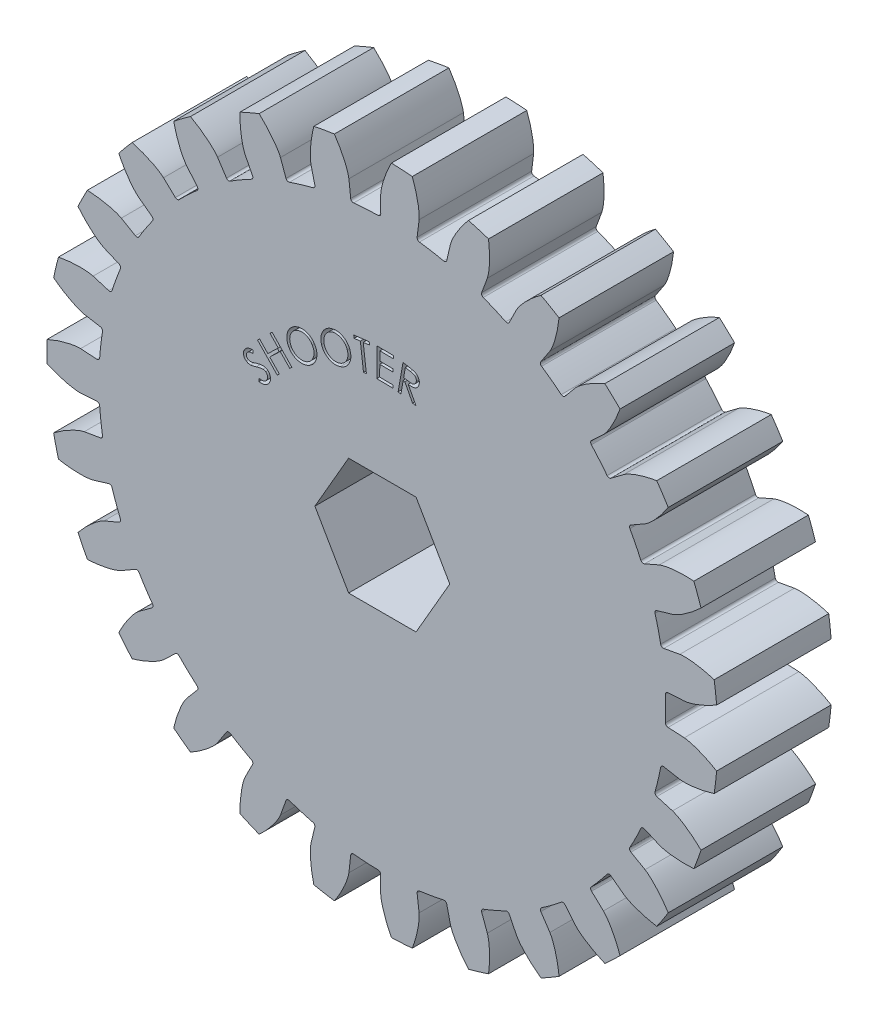
from build123d import *

# Parameters (mm, degrees)
SKETCH1_R              = 37.202020202
BODYBLANK_DEPTH        = 12.7
TOOTHCUTMASTER_DEPTH   = 13.7
TOOTHCUTSPATTERN_COUNT = 27
CUT_EXTRUDE1_DEPTH     = 13.7000001
SHOOTER_DEPTH          = 1.27


with BuildPart() as part:
    # Sketch1 → BodyBlank (new body)
    with BuildSketch(Plane.XY):
        Circle(SKETCH1_R)
    extrude(amount=BODYBLANK_DEPTH)

    # EqDrivenInvoluteCurves → ToothCutMaster (cut, through all)
    with BuildSketch(Plane.XY.offset(12.7)):
        with BuildLine():
            Line((31.681619769, 1.6690338), (33.486677538, 1.764126868))
            add(Edge.make_bspline(
                [(33.486677538, 1.764126868), (33.492388197, 1.764485944), (33.50839531, 1.765672924), (33.538618099, 1.768627279), (33.58787541, 1.774457047), (33.650547397, 1.78336854), (33.731442881, 1.796590504), (33.826591419, 1.814357912), (33.930994408, 1.836180458), (34.044395442, 1.862401828), (34.15735783, 1.890754256), (34.269875909, 1.921078839), (34.381804891, 1.953128433), (34.517192773, 1.994127781), (34.679259957, 2.046315997), (34.868267652, 2.111726934), (35.082113124, 2.191118913), (35.299479381, 2.277603643), (35.512882182, 2.367282562), (35.72791402, 2.463158514), (35.935554052, 2.559655249), (36.150605398, 2.665286344), (36.348791798, 2.765534392), (36.570117434, 2.883829579), (36.748521521, 2.981040043), (36.932199912, 3.086449102), (37.021506506, 3.138489053), (37.067109149, 3.165395146)],
                knots=[0, 0, 0, 0, 0, 0.005376749, 0.015083688, 0.02853182, 0.04661014, 0.064854849, 0.092110526, 0.119476176, 0.146842496, 0.174208854, 0.201574956, 0.228941013, 0.256307345, 0.307035032, 0.361767352, 0.416499661, 0.471231937, 0.525964282, 0.580696616, 0.635428982, 0.690161387, 0.744893688, 0.799626082, 0.854358407, 0.909090914, 0.909090914, 0.909090914, 0.909090914, 0.909090914], degree=4))
            ThreePointArc((37.067109149, 3.165395146), (37.202020202, 0), (37.067109149, -3.165395146))
            add(Edge.make_bspline(
                [(33.486677538, -1.764126868), (33.492388197, -1.764485944), (33.50839531, -1.765672924), (33.538618099, -1.768627279), (33.58787541, -1.774457047), (33.650547397, -1.78336854), (33.731442881, -1.796590504), (33.826591419, -1.814357912), (33.930994408, -1.836180458), (34.044395442, -1.862401828), (34.15735783, -1.890754256), (34.269875909, -1.921078839), (34.381804891, -1.953128433), (34.517192773, -1.994127781), (34.679259957, -2.046315997), (34.868267652, -2.111726934), (35.082113124, -2.191118913), (35.299479381, -2.277603643), (35.512882182, -2.367282562), (35.72791402, -2.463158514), (35.935554052, -2.559655249), (36.150605398, -2.665286344), (36.348791798, -2.765534392), (36.570117434, -2.883829579), (36.748521521, -2.981040043), (36.932199912, -3.086449102), (37.021506506, -3.138489053), (37.067109149, -3.165395146)],
                knots=[0, 0, 0, 0, 0, 0.005376749, 0.015083688, 0.02853182, 0.04661014, 0.064854849, 0.092110526, 0.119476176, 0.146842496, 0.174208854, 0.201574956, 0.228941013, 0.256307345, 0.307035032, 0.361767352, 0.416499661, 0.471231937, 0.525964282, 0.580696616, 0.635428982, 0.690161387, 0.744893688, 0.799626082, 0.854358407, 0.909090914, 0.909090914, 0.909090914, 0.909090914, 0.909090914], degree=4))
            Line((33.486677538, -1.764126868), (31.681619769, -1.6690338))
            ThreePointArc((31.681619769, -1.6690338), (31.47695942, -1.571935981), (31.399901128, -1.358919867))
            ThreePointArc((31.399901128, -1.358919867), (31.429292929, 0), (31.399901128, 1.358919867))
            ThreePointArc((31.399901128, 1.358919867), (31.47695942, 1.571935981), (31.681619769, 1.6690338))
        make_face()
    toothcutmaster = extrude(amount=-TOOTHCUTMASTER_DEPTH, mode=Mode.SUBTRACT)

    # ToothCutsPattern: ToothCutMaster ×27 about axis
    toothcutspattern_axis = Axis((0, 0, 12.7), (0, 0, -1))
    for i in range(1, TOOTHCUTSPATTERN_COUNT):
        add(toothcutmaster.rotate(toothcutspattern_axis, i * 360 / TOOTHCUTSPATTERN_COUNT), mode=Mode.SUBTRACT)

    # Sketch2 → Cut-Extrude1 (cut, through all)
    with BuildSketch(Plane.XY.offset(12.7)):
        Polygon((3.739497694, 6.477), (-3.739497694, 6.477), (-7.478995387, 0), (-3.739497694, -6.477), (3.739497694, -6.477), (7.478995387, 0), align=None)
    extrude(amount=-CUT_EXTRUDE1_DEPTH, mode=Mode.SUBTRACT)

    # Sketch3 → Shooter (cut)
    with BuildSketch(Plane.XY.offset(12.7)):
        with BuildLine():
            Line((-13.676549152, 8.860884825), (-13.649200394, 9.171897445))
            add(Edge.make_bspline(
                [(-13.649200394, 9.171897445), (-13.602408385, 9.166680453), (-13.51261279, 9.156668852), (-13.38270523, 9.154427095), (-13.264172616, 9.164295133), (-13.156873614, 9.185280047), (-13.061029192, 9.219099513), (-12.976385867, 9.26429037), (-12.903310114, 9.322295907), (-12.864626466, 9.369577776), (-12.845274112, 9.393231579)],
                knots=[0, 0, 0, 0, 0.000141193, 0.000270955, 0.000389057, 0.000497451, 0.000598034, 0.000692803, 0.000784186, 0.000875669, 0.000875669, 0.000875669, 0.000875669], degree=3))
            add(Edge.make_bspline(
                [(-12.845274112, 9.393231579), (-12.830706223, 9.414942367), (-12.801855038, 9.457939808), (-12.768899273, 9.52805102), (-12.744293446, 9.601228011), (-12.729540513, 9.676933843), (-12.722690955, 9.752901013), (-12.726398022, 9.826998905), (-12.740445875, 9.898213003), (-12.765136941, 9.965151988), (-12.796186134, 10.028393193), (-12.836626395, 10.084534587), (-12.882196025, 10.135870749), (-12.918156655, 10.163962817), (-12.936224633, 10.178077333)],
                knots=[0, 0, 0, 0, 7.8341e-05, 0.000155152, 0.00023158, 0.000309414, 0.000386, 0.000459877, 0.000531225, 0.000602844, 0.000673384, 0.00074185, 0.000809833, 0.000878481, 0.000878481, 0.000878481, 0.000878481], degree=3))
            add(Edge.make_bspline(
                [(-12.936224633, 10.178077333), (-12.958266241, 10.192453363), (-13.002917895, 10.221576171), (-13.079209415, 10.25086524), (-13.162145615, 10.269915444), (-13.219988696, 10.272687976), (-13.249781324, 10.274115995)],
                knots=[0, 0, 0, 0, 7.8753e-05, 0.000159538, 0.000243631, 0.000332948, 0.000332948, 0.000332948, 0.000332948], degree=3))
            add(Edge.make_bspline(
                [(-13.249781324, 10.274115995), (-13.272263415, 10.273959225), (-13.319418096, 10.273630413), (-13.393547326, 10.26755283), (-13.474131241, 10.256486648), (-13.561504783, 10.241042386), (-13.655464981, 10.221293058), (-13.755951625, 10.196952637), (-13.863136563, 10.168411627), (-13.936319321, 10.146283615), (-13.974205402, 10.134828134)],
                knots=[0, 0, 0, 0, 6.743e-05, 0.00014143, 0.000222924, 0.000311386, 0.000407559, 0.000510915, 0.000621533, 0.000740266, 0.000740266, 0.000740266, 0.000740266], degree=3))
            add(Edge.make_bspline(
                [(-13.974205402, 10.134828134), (-14.011885487, 10.123392973), (-14.083872657, 10.101546289), (-14.187606508, 10.073446187), (-14.281325363, 10.048034062), (-14.365575468, 10.027958409), (-14.440078047, 10.01138812), (-14.505127146, 10.000953393), (-14.560431116, 9.993068278), (-14.594302591, 9.991703846), (-14.609587013, 9.99108815)],
                knots=[0, 0, 0, 0, 0.000118123, 0.000225672, 0.000322401, 0.000409405, 0.000485499, 0.000551268, 0.000607042, 0.000652906, 0.000652906, 0.000652906, 0.000652906], degree=3))
            add(Edge.make_bspline(
                [(-14.609587013, 9.99108815), (-14.632497937, 9.991139315), (-14.677569188, 9.99123997), (-14.74415427, 9.997807874), (-14.808319923, 10.009300949), (-14.870509648, 10.025139564), (-14.930530837, 10.046207394), (-14.988266306, 10.072402111), (-15.044247922, 10.102872733), (-15.079174433, 10.127080268), (-15.096776516, 10.139280257)],
                knots=[0, 0, 0, 0, 6.8702e-05, 0.000135153, 0.000200403, 0.000264112, 0.000327475, 0.000390956, 0.000454153, 0.000518362, 0.000518362, 0.000518362, 0.000518362], degree=3))
            add(Edge.make_bspline(
                [(-15.096776516, 10.139280257), (-15.123247439, 10.159789511), (-15.175480361, 10.200258757), (-15.242486536, 10.27229959), (-15.29842488, 10.351601376), (-15.343765691, 10.437111831), (-15.376022389, 10.528271011), (-15.396031691, 10.622794096), (-15.403071947, 10.720158752), (-15.396467838, 10.819155858), (-15.377302892, 10.917608738), (-15.346394036, 11.013418768), (-15.301796177, 11.104844494), (-15.26408442, 11.161342817), (-15.244968624, 11.189981379)],
                knots=[0, 0, 0, 0, 0.00010033, 0.000197972, 0.000293794, 0.000390807, 0.000487368, 0.000582919, 0.000679847, 0.000779269, 0.000879682, 0.000980045, 0.001080458, 0.001183677, 0.001183677, 0.001183677, 0.001183677], degree=3))
            add(Edge.make_bspline(
                [(-15.244968624, 11.189981379), (-15.222411396, 11.218855738), (-15.177751313, 11.276022835), (-15.097417976, 11.349708782), (-15.00848348, 11.412076761), (-14.927433723, 11.455805256), (-14.856805717, 11.484126289), (-14.7985123, 11.503500403), (-14.734892855, 11.519154071), (-14.666228154, 11.531584444), (-14.592601215, 11.541802834), (-14.514104053, 11.549372012), (-14.430283904, 11.553891368), (-14.372782264, 11.554239664), (-14.343095627, 11.55441948)],
                knots=[0, 0, 0, 0, 0.000109773, 0.000217336, 0.000325505, 0.00043505, 0.000492686, 0.000553628, 0.000619187, 0.000689045, 0.000762891, 0.000842126, 0.000925563, 0.001014615, 0.001014615, 0.001014615, 0.001014615], degree=3))
            Line((-14.343095627, 11.55441948), (-14.336099433, 11.23259456))
            add(Edge.make_bspline(
                [(-14.336099433, 11.23259456), (-14.359848861, 11.231859434), (-14.405673926, 11.230440992), (-14.471836176, 11.226567948), (-14.532960409, 11.221721449), (-14.589020206, 11.21488684), (-14.640074895, 11.205726369), (-14.686343573, 11.196134674), (-14.727423763, 11.183726307), (-14.775457518, 11.166399716), (-14.829157979, 11.138675548), (-14.888315694, 11.099027551), (-14.940630328, 11.050311411), (-14.970447849, 11.012926749), (-14.985473431, 10.99408795)],
                knots=[0, 0, 0, 0, 7.1279e-05, 0.000137535, 0.000198805, 0.00025521, 0.000306864, 0.000354396, 0.000396857, 0.000435492, 0.000507455, 0.000577489, 0.000648598, 0.00072083, 0.00072083, 0.00072083, 0.00072083], degree=3))
            add(Edge.make_bspline(
                [(-14.985473431, 10.99408795), (-15.002407198, 10.968792631), (-15.035063496, 10.920011312), (-15.066051161, 10.839146091), (-15.0805596, 10.757023217), (-15.077765416, 10.674850524), (-15.059885622, 10.596094803), (-15.025688306, 10.524513144), (-14.978130771, 10.460446752), (-14.936682993, 10.426783116), (-14.915511492, 10.409587749)],
                knots=[0, 0, 0, 0, 9.1084e-05, 0.000175653, 0.00025763, 0.000339716, 0.00042071, 0.000498095, 0.000576199, 0.00065775, 0.00065775, 0.00065775, 0.00065775], degree=3))
            add(Edge.make_bspline(
                [(-14.915511492, 10.409587749), (-14.901496891, 10.400152045), (-14.873468795, 10.381281381), (-14.828035178, 10.35873723), (-14.780562262, 10.339721976), (-14.729528159, 10.32644097), (-14.67350518, 10.31769302), (-14.611249212, 10.31680734), (-14.54209942, 10.319510712), (-14.494212285, 10.326440814), (-14.469027117, 10.330085546)],
                knots=[0, 0, 0, 0, 5.0634e-05, 0.000101265, 0.000151815, 0.000203805, 0.000259124, 0.000321483, 0.000390247, 0.000466532, 0.000466532, 0.000466532, 0.000466532], degree=3))
            add(Edge.make_bspline(
                [(-14.469027117, 10.330085546), (-14.460326457, 10.331956253), (-14.439459906, 10.336442719), (-14.403159109, 10.345431283), (-14.356571189, 10.358379781), (-14.299985223, 10.374781035), (-14.23319203, 10.394680368), (-14.156541531, 10.418315971), (-14.069281577, 10.444835518), (-14.007895082, 10.464223128), (-13.975477438, 10.474461547)],
                knots=[0, 0, 0, 0, 2.6698e-05, 6.4028e-05, 0.000112168, 0.000171751, 0.000240773, 0.000321248, 0.000412385, 0.000514373, 0.000514373, 0.000514373, 0.000514373], degree=3))
            add(Edge.make_bspline(
                [(-13.975477438, 10.474461547), (-13.93631613, 10.486533257), (-13.860389599, 10.509938068), (-13.749133157, 10.540666071), (-13.644065485, 10.565436428), (-13.545453813, 10.585369617), (-13.453366639, 10.600013729), (-13.367665996, 10.610076665), (-13.288195131, 10.613888017), (-13.214253442, 10.612740095), (-13.145045493, 10.606812514), (-13.079070389, 10.597623911), (-13.016176055, 10.583125589), (-12.955481985, 10.566610774), (-12.898221221, 10.544374262), (-12.843037081, 10.519862804), (-12.790764966, 10.490524963), (-12.75797436, 10.467932583), (-12.741603239, 10.456653054)],
                knots=[0, 0, 0, 0, 0.000122936, 0.00023835, 0.000346184, 0.000446719, 0.000540095, 0.000625854, 0.000705447, 0.0007786, 0.000847528, 0.000913729, 0.000978231, 0.001041046, 0.001102236, 0.001162295, 0.001222094, 0.001281717, 0.001281717, 0.001281717, 0.001281717], degree=3))
            add(Edge.make_bspline(
                [(-12.741603239, 10.456653054), (-12.719417602, 10.439474519), (-12.675646555, 10.405582211), (-12.616495626, 10.347805544), (-12.56522513, 10.284378464), (-12.519445572, 10.217243979), (-12.482498106, 10.144082022), (-12.45198717, 10.066595434), (-12.428375947, 9.983947903), (-12.412256495, 9.897718378), (-12.402907667, 9.809837885), (-12.403388101, 9.722528142), (-12.410425204, 9.637010353), (-12.427439367, 9.553274965), (-12.452788185, 9.471442896), (-12.486912825, 9.391469562), (-12.529002603, 9.313255271), (-12.562839203, 9.26382744), (-12.580054761, 9.238679296)],
                knots=[0, 0, 0, 0, 8.4132e-05, 0.000165989, 0.000247344, 0.000328488, 0.000409272, 0.000492656, 0.000578011, 0.0006667, 0.000755554, 0.000842689, 0.000928256, 0.001012576, 0.001098476, 0.001184829, 0.00127305, 0.001364427, 0.001364427, 0.001364427, 0.001364427], degree=3))
            add(Edge.make_bspline(
                [(-12.580054761, 9.238679296), (-12.594406813, 9.219795286), (-12.622753549, 9.182497481), (-12.669703973, 9.131005982), (-12.718505467, 9.082873288), (-12.771084337, 9.039593217), (-12.82624796, 9.000120943), (-12.88459549, 8.964987833), (-12.945535016, 8.933835761), (-13.009662441, 8.906819251), (-13.077516169, 8.884568009), (-13.149730364, 8.866544686), (-13.226578309, 8.85427214), (-13.307904313, 8.845994545), (-13.393700599, 8.842114691), (-13.484121841, 8.843824447), (-13.579039819, 8.849201522), (-13.643509001, 8.856926044), (-13.676549152, 8.860884825)],
                knots=[0, 0, 0, 0, 7.1123e-05, 0.000140475, 0.000208841, 0.000276594, 0.00034454, 0.000412168, 0.000480719, 0.000549703, 0.000620701, 0.000694744, 0.000772747, 0.000853943, 0.00093989, 0.001030214, 0.001125153, 0.001224959, 0.001224959, 0.001224959, 0.001224959], degree=3))
        make_face()
        Polygon((-13.846816766, 12.777965994), (-13.617214403, 12.998664111), (-12.696260877, 12.042093598), (-11.536800741, 13.157668518), (-12.457754266, 14.114239031), (-12.228151903, 14.335573165), (-10.033255068, 12.054813951), (-10.262857431, 11.833479816), (-11.3224628, 12.934426331), (-12.481922936, 11.818851411), (-11.422317568, 10.717904896), (-11.651919931, 10.497206779), align=None)
        with BuildLine():
            add(Edge.make_bspline(
                [(-9.794914784, 16.074500039), (-9.743699079, 16.103488778), (-9.643273454, 16.160330957), (-9.486035071, 16.227249705), (-9.327572254, 16.277716806), (-9.16774008, 16.312852634), (-9.006017765, 16.328912748), (-8.843276627, 16.32973514), (-8.678911428, 16.313803023), (-8.515387069, 16.280277025), (-8.355414689, 16.233500954), (-8.203397107, 16.171428833), (-8.060576826, 16.096231832), (-7.927559869, 16.00663976), (-7.804288105, 15.90305321), (-7.690878883, 15.785656932), (-7.585289701, 15.655927236), (-7.525461546, 15.560229152), (-7.49507504, 15.511624438)],
                knots=[0, 0, 0, 0, 0.000176442, 0.000345974, 0.000511516, 0.000674809, 0.000835936, 0.000998122, 0.00116235, 0.001330366, 0.001498199, 0.001661661, 0.001822125, 0.001981592, 0.002141855, 0.002304224, 0.0024707, 0.002642519, 0.002642519, 0.002642519, 0.002642519], degree=3))
            add(Edge.make_bspline(
                [(-7.49507504, 15.511624438), (-7.467191281, 15.462080473), (-7.41217559, 15.364328389), (-7.347287065, 15.211098611), (-7.299331177, 15.055656524), (-7.267383586, 14.898434982), (-7.250936381, 14.739050431), (-7.252858654, 14.577498034), (-7.269946016, 14.413884014), (-7.303841204, 14.250481493), (-7.351548508, 14.090713018), (-7.413184804, 13.938323771), (-7.489460315, 13.796107284), (-7.578075979, 13.662666288), (-7.681217542, 13.539547705), (-7.797461191, 13.425929394), (-7.927333817, 13.322030004), (-8.021944886, 13.262009307), (-8.070034976, 13.231501241)],
                knots=[0, 0, 0, 0, 0.000170454, 0.000336312, 0.000498058, 0.000657717, 0.000816882, 0.0009778, 0.001141523, 0.001309665, 0.001477681, 0.001641143, 0.001801905, 0.001961018, 0.002120872, 0.002282786, 0.002447971, 0.002618727, 0.002618727, 0.002618727, 0.002618727], degree=3))
            add(Edge.make_bspline(
                [(-8.070034976, 13.231501241), (-8.120192758, 13.203142993), (-8.218923021, 13.147322794), (-8.373699172, 13.082136822), (-8.529858377, 13.032353774), (-8.688066952, 12.999825316), (-8.848328632, 12.984043507), (-9.010324446, 12.983639936), (-9.174050319, 13.001629023), (-9.337620938, 13.034292184), (-9.497042409, 13.082244224), (-9.64896035, 13.143557066), (-9.791278678, 13.217713695), (-9.923259047, 13.306557193), (-10.045772202, 13.407777897), (-10.158211417, 13.522647511), (-10.26160096, 13.65017642), (-10.320756131, 13.743704616), (-10.350794191, 13.791196754)],
                knots=[0, 0, 0, 0, 0.000172737, 0.000340015, 0.000502747, 0.00066378, 0.000823577, 0.000985126, 0.001148849, 0.001316865, 0.001484881, 0.001647514, 0.001807682, 0.001965383, 0.002123936, 0.002283596, 0.002446894, 0.002615357, 0.002615357, 0.002615357, 0.002615357], degree=3))
            add(Edge.make_bspline(
                [(-10.350794191, 13.791196754), (-10.369446457, 13.823834109), (-10.406642634, 13.888919222), (-10.454522602, 13.989700479), (-10.495822339, 14.092215082), (-10.529040486, 14.196545505), (-10.557185342, 14.302492265), (-10.576125449, 14.41044709), (-10.590175901, 14.519922301), (-10.595517911, 14.630473623), (-10.594088711, 14.741099723), (-10.586961894, 14.850373706), (-10.571445327, 14.957659674), (-10.548955477, 15.062713695), (-10.520682022, 15.166230363), (-10.484035267, 15.267125841), (-10.441383251, 15.366550637), (-10.391241134, 15.463009865), (-10.335424208, 15.556638938), (-10.273711164, 15.645606383), (-10.206818879, 15.729770565), (-10.134814145, 15.80884796), (-10.057481391, 15.882780902), (-9.975398596, 15.952161966), (-9.888135673, 16.017005448), (-9.826162807, 16.055227617), (-9.794914784, 16.074500039)],
                knots=[0, 0, 0, 0, 0.00011274, 0.000224826, 0.000334428, 0.000444046, 0.00055311, 0.000663016, 0.000772592, 0.000884042, 0.000994716, 0.001104377, 0.001212313, 0.001319591, 0.001426527, 0.001533956, 0.001641354, 0.001750871, 0.001859838, 0.001968165, 0.002075441, 0.002182142, 0.002288753, 0.002396166, 0.00250442, 0.002614517, 0.002614517, 0.002614517, 0.002614517], degree=3))
        make_face()
        with BuildLine():
            add(Edge.make_bspline(
                [(-9.623190024, 15.815640865), (-9.647781371, 15.800268066), (-9.696937751, 15.769538918), (-9.766568268, 15.718003726), (-9.83249605, 15.662417654), (-9.894502093, 15.602430723), (-9.952201152, 15.537702641), (-10.005536648, 15.468431542), (-10.05648643, 15.396043652), (-10.101406823, 15.318558402), (-10.143078135, 15.239140273), (-10.177724549, 15.157193732), (-10.208044076, 15.074838109), (-10.231439787, 14.990715799), (-10.249918377, 14.905808395), (-10.263009867, 14.819367464), (-10.268845304, 14.731752949), (-10.27034799, 14.643419775), (-10.266066297, 14.554979955), (-10.254982488, 14.467061655), (-10.238669097, 14.380110622), (-10.215996102, 14.294159877), (-10.1881848, 14.209116972), (-10.154265042, 14.124744785), (-10.114350695, 14.041427164), (-10.08337799, 13.987539341), (-10.067766347, 13.960377443)],
                knots=[0, 0, 0, 0, 8.6976e-05, 0.00017386, 0.000259611, 0.000345521, 0.00043246, 0.000519481, 0.000607695, 0.000697794, 0.000787967, 0.000876575, 0.000964495, 0.001051073, 0.001138272, 0.001225072, 0.001313072, 0.001401488, 0.001490006, 0.00157844, 0.00166713, 0.001755216, 0.001844919, 0.001935388, 0.00202784, 0.002121801, 0.002121801, 0.002121801, 0.002121801], degree=3))
            add(Edge.make_bspline(
                [(-10.067766347, 13.960377443), (-10.043113583, 13.921235967), (-9.994653582, 13.844295468), (-9.909400354, 13.739951638), (-9.818733344, 13.644702392), (-9.718657707, 13.561919628), (-9.611531913, 13.489410676), (-9.496012733, 13.429092522), (-9.373597567, 13.37837899), (-9.244544652, 13.340205916), (-9.112975723, 13.313690461), (-8.981614799, 13.299414064), (-8.852269357, 13.29788219), (-8.724554189, 13.310042175), (-8.599166511, 13.335818901), (-8.475359621, 13.373645468), (-8.353325779, 13.424176673), (-8.275891879, 13.468108791), (-8.236671595, 13.490360416)],
                knots=[0, 0, 0, 0, 0.000138652, 0.000272548, 0.00040344, 0.000532594, 0.000661366, 0.000790816, 0.000922864, 0.001058288, 0.001193873, 0.001325006, 0.001454123, 0.001581267, 0.001709119, 0.001837478, 0.001969183, 0.002104357, 0.002104357, 0.002104357, 0.002104357], degree=3))
            add(Edge.make_bspline(
                [(-8.236671595, 13.490360416), (-8.210763134, 13.506302809), (-8.15927451, 13.537985583), (-8.087154359, 13.591875936), (-8.018469128, 13.648629461), (-7.954302235, 13.709441469), (-7.895059439, 13.77487373), (-7.839537397, 13.843465242), (-7.788631304, 13.916191957), (-7.742158387, 13.992378956), (-7.701315003, 14.071383712), (-7.665212795, 14.15193277), (-7.635539078, 14.233851754), (-7.611115163, 14.317071208), (-7.592462545, 14.401613164), (-7.580893505, 14.487584406), (-7.573332693, 14.574617436), (-7.57306608, 14.662619072), (-7.57805543, 14.750991312), (-7.588851317, 14.838749348), (-7.605490719, 14.925636369), (-7.627791209, 15.011458213), (-7.655597637, 15.096422827), (-7.690624911, 15.179676791), (-7.729584797, 15.262987051), (-7.760527174, 15.316579349), (-7.776194832, 15.343715785)],
                knots=[0, 0, 0, 0, 9.1219e-05, 0.000181283, 0.000269801, 0.000358427, 0.000446218, 0.000534423, 0.000623001, 0.000712336, 0.000801944, 0.000889641, 0.000976963, 0.001063105, 0.001149683, 0.001236392, 0.001323173, 0.001411582, 0.001500134, 0.001588568, 0.001676633, 0.001765334, 0.001854433, 0.001944553, 0.002036157, 0.002130118, 0.002130118, 0.002130118, 0.002130118], degree=3))
            add(Edge.make_bspline(
                [(-7.776194832, 15.343715785), (-7.792613339, 15.370223291), (-7.825025215, 15.422551923), (-7.878782514, 15.496320402), (-7.935511726, 15.565728304), (-7.996765772, 15.629649852), (-8.060835587, 15.689662236), (-8.128720852, 15.744579282), (-8.199920493, 15.795030707), (-8.274945754, 15.839950933), (-8.352559709, 15.879912351), (-8.431769001, 15.915182299), (-8.513366711, 15.943732908), (-8.596554742, 15.96749282), (-8.682075539, 15.98497647), (-8.76928346, 15.998213332), (-8.858600006, 16.003995555), (-8.949059744, 16.005590166), (-9.039523803, 16.000904345), (-9.128780294, 15.991617673), (-9.216133603, 15.976342239), (-9.301435251, 15.955134106), (-9.385069688, 15.929217633), (-9.466610211, 15.89720003), (-9.546458437, 15.859858971), (-9.597524221, 15.830431295), (-9.623190024, 15.815640865)],
                knots=[0, 0, 0, 0, 9.3512e-05, 0.000184602, 0.000273611, 0.000362237, 0.000449991, 0.000536807, 0.000623978, 0.000711566, 0.000798896, 0.000885753, 0.000971448, 0.001058026, 0.001145093, 0.001233151, 0.001322421, 0.00141338, 0.001504439, 0.001593992, 0.001682453, 0.001770226, 0.001857529, 0.00194493, 0.002032844, 0.002121677, 0.002121677, 0.002121677, 0.002121677], degree=3))
        make_face(mode=Mode.SUBTRACT)
        with BuildLine():
            add(Edge.make_bspline(
                [(-5.679581034, 17.965467256), (-5.623227247, 17.981737442), (-5.512429308, 18.013726473), (-5.344379399, 18.043762935), (-5.178855924, 18.056335195), (-5.015777959, 18.053816005), (-4.855191361, 18.032756826), (-4.69693376, 17.996774692), (-4.541335312, 17.943191744), (-4.389911346, 17.874407677), (-4.245864226, 17.791574107), (-4.11197521, 17.697232581), (-3.990676035, 17.591309745), (-3.881740468, 17.474083431), (-3.785253003, 17.345491502), (-3.70125568, 17.205652691), (-3.629269341, 17.054851668), (-3.592433444, 16.948449133), (-3.573726667, 16.89441357)],
                knots=[0, 0, 0, 0, 0.000175883, 0.000345805, 0.000511024, 0.00067324, 0.000834173, 0.000996018, 0.001159337, 0.001326986, 0.00149423, 0.001657111, 0.001817579, 0.001976442, 0.002136337, 0.00229897, 0.002465116, 0.002636555, 0.002636555, 0.002636555, 0.002636555], degree=3))
            add(Edge.make_bspline(
                [(-3.573726667, 16.89441357), (-3.557789711, 16.839770221), (-3.526423029, 16.732222671), (-3.498853831, 16.568437193), (-3.486928444, 16.40676368), (-3.492266455, 16.246714125), (-3.51322849, 16.088137823), (-3.550844611, 15.931213872), (-3.605793037, 15.776449752), (-3.675060875, 15.624913882), (-3.758351164, 15.480710311), (-3.852552062, 15.346548128), (-3.958905857, 15.225821975), (-4.075847762, 15.117122032), (-4.203566801, 15.020521909), (-4.342744546, 14.937046757), (-4.492304394, 14.865092065), (-4.598150794, 14.828647822), (-4.651776547, 14.810183802)],
                knots=[0, 0, 0, 0, 0.000170639, 0.000335847, 0.000497166, 0.000656252, 0.000815375, 0.000976272, 0.001139406, 0.00130732, 0.001475432, 0.001638313, 0.001798303, 0.001957166, 0.002116553, 0.002277768, 0.002443339, 0.002613366, 0.002613366, 0.002613366, 0.002613366], degree=3))
            add(Edge.make_bspline(
                [(-4.651776547, 14.810183802), (-4.706827392, 14.79395911), (-4.815346891, 14.761976033), (-4.980785428, 14.734874409), (-5.143818086, 14.7223415), (-5.305227175, 14.725767398), (-5.464566113, 14.747241325), (-5.62209896, 14.784209599), (-5.777351789, 14.838140159), (-5.928570183, 14.907723076), (-6.072812113, 14.990371026), (-6.206226743, 15.084627495), (-6.327339939, 15.189568473), (-6.436081001, 15.305091677), (-6.531782223, 15.431684857), (-6.614864211, 15.56868851), (-6.685412293, 15.716187055), (-6.721514699, 15.820215756), (-6.73982242, 15.872969259)],
                knots=[0, 0, 0, 0, 0.000172033, 0.000339122, 0.000501756, 0.000662078, 0.000822461, 0.000983212, 0.001146737, 0.001314651, 0.001481895, 0.001644776, 0.001803929, 0.001961863, 0.002119851, 0.002279105, 0.002441832, 0.002609251, 0.002609251, 0.002609251, 0.002609251], degree=3))
            add(Edge.make_bspline(
                [(-6.73982242, 15.872969259), (-6.750736813, 15.909084129), (-6.772386136, 15.980720045), (-6.795394163, 16.089902366), (-6.812449371, 16.198786076), (-6.820833551, 16.307849053), (-6.823923532, 16.417017588), (-6.818480765, 16.526217296), (-6.806594185, 16.635686539), (-6.786589311, 16.744330062), (-6.760995839, 16.851795681), (-6.727617621, 16.955915929), (-6.688824365, 17.056919134), (-6.64385635, 17.154185995), (-6.5918005, 17.247810952), (-6.533349904, 17.337734909), (-6.469058931, 17.424648949), (-6.39839389, 17.507004856), (-6.323001404, 17.585189015), (-6.242924363, 17.657693884), (-6.158623697, 17.723995916), (-6.070666704, 17.784518649), (-5.979061058, 17.839463161), (-5.883071389, 17.887781138), (-5.783404642, 17.930824994), (-5.714321709, 17.953875523), (-5.679581034, 17.965467256)],
                knots=[0, 0, 0, 0, 0.000113136, 0.000224412, 0.000334421, 0.000443544, 0.000552333, 0.000661846, 0.000771274, 0.000882432, 0.000993037, 0.001102461, 0.001210181, 0.001317459, 0.001423651, 0.001531264, 0.001639007, 0.001747729, 0.001856579, 0.001964649, 0.002071531, 0.002178088, 0.002284765, 0.002391714, 0.002500281, 0.002610108, 0.002610108, 0.002610108, 0.002610108], degree=3))
        make_face()
        with BuildLine():
            add(Edge.make_bspline(
                [(-5.572094055, 17.674807199), (-5.599556476, 17.66536464), (-5.654243837, 17.646561177), (-5.733993603, 17.612935955), (-5.810379522, 17.573326832), (-5.883909418, 17.528391882), (-5.954878095, 17.478951301), (-6.023488215, 17.424825405), (-6.088308175, 17.364642716), (-6.150058296, 17.300086771), (-6.208873829, 17.23257329), (-6.261220744, 17.161035921), (-6.309506794, 17.087973346), (-6.351222545, 17.01168993), (-6.389195792, 16.933675071), (-6.420778481, 16.852500289), (-6.447758714, 16.769133966), (-6.468540487, 16.683422479), (-6.483814711, 16.596315483), (-6.493359859, 16.508565945), (-6.497149763, 16.420190617), (-6.495432011, 16.331355147), (-6.486961533, 16.242132602), (-6.472689164, 16.152564663), (-6.453507533, 16.062290198), (-6.435396911, 16.002812196), (-6.42626573, 15.972824026)],
                knots=[0, 0, 0, 0, 8.7107e-05, 0.00017346, 0.000259367, 0.000344993, 0.0004318, 0.000518714, 0.000606935, 0.000696899, 0.00078665, 0.000875312, 0.000962634, 0.001049182, 0.001135946, 0.001222755, 0.001310251, 0.001398641, 0.001487103, 0.00157539, 0.001663243, 0.001752306, 0.001841732, 0.001931867, 0.002024309, 0.002118312, 0.002118312, 0.002118312, 0.002118312], degree=3))
            add(Edge.make_bspline(
                [(-6.42626573, 15.972824026), (-6.411158248, 15.92926557), (-6.381437623, 15.84357395), (-6.323883686, 15.722187901), (-6.255851189, 15.610241997), (-6.178818674, 15.506491566), (-6.091109978, 15.411904975), (-5.993251503, 15.326245827), (-5.885208356, 15.249908891), (-5.76902178, 15.182898627), (-5.647085356, 15.127397916), (-5.522760036, 15.083927864), (-5.397194561, 15.052810718), (-5.27032168, 15.035664566), (-5.142425345, 15.031907521), (-5.013624583, 15.041207485), (-4.883437019, 15.062178253), (-4.798055785, 15.086999974), (-4.754811403, 15.099571823)],
                knots=[0, 0, 0, 0, 0.000138238, 0.000271953, 0.000402082, 0.000530685, 0.000658955, 0.00078831, 0.000920138, 0.001055195, 0.001190105, 0.001321453, 0.001449796, 0.001577523, 0.001704784, 0.001832933, 0.00196447, 0.002099465, 0.002099465, 0.002099465, 0.002099465], degree=3))
            add(Edge.make_bspline(
                [(-4.754811403, 15.099571823), (-4.726060499, 15.109399621), (-4.668984802, 15.128909563), (-4.586377958, 15.16405702), (-4.507024096, 15.203554784), (-4.431144688, 15.248174986), (-4.358686361, 15.297965386), (-4.289019199, 15.352094439), (-4.222964281, 15.411209405), (-4.160755611, 15.474952173), (-4.102393266, 15.541771816), (-4.049543128, 15.612097014), (-4.001518361, 15.684825648), (-3.959027484, 15.760288127), (-3.922063188, 15.83836224), (-3.8898402, 15.918704849), (-3.864244512, 16.002026094), (-3.842861874, 16.087299687), (-3.828150965, 16.174308641), (-3.817171382, 16.261928501), (-3.814816626, 16.350181641), (-3.816039693, 16.438583237), (-3.825046831, 16.527283013), (-3.837765107, 16.616700628), (-3.858544686, 16.706166719), (-3.875968289, 16.765384657), (-3.884739287, 16.79519482)],
                knots=[0, 0, 0, 0, 9.1128e-05, 0.000180906, 0.000269081, 0.000356891, 0.000444744, 0.000532657, 0.000621392, 0.000710444, 0.000799713, 0.000887357, 0.000974147, 0.001061005, 0.001146921, 0.001233139, 0.001320442, 0.001408215, 0.001496677, 0.001585035, 0.001672863, 0.00176129, 0.001850082, 0.001940121, 0.00203208, 0.002125297, 0.002125297, 0.002125297, 0.002125297], degree=3))
            add(Edge.make_bspline(
                [(-3.884739287, 16.79519482), (-3.89457225, 16.824573964), (-3.914028907, 16.882706997), (-3.948891019, 16.966853738), (-3.989616746, 17.04642184), (-4.03307504, 17.1232283), (-4.082381744, 17.195632634), (-4.13577513, 17.26478352), (-4.194524277, 17.329333006), (-4.256674618, 17.390618537), (-4.323015049, 17.4470247), (-4.392032189, 17.499520451), (-4.465150114, 17.545821135), (-4.540776542, 17.588057297), (-4.619712048, 17.624842578), (-4.701757525, 17.656760997), (-4.78658893, 17.684255263), (-4.874278258, 17.705464132), (-4.962985332, 17.722187736), (-5.051795334, 17.732835361), (-5.140170847, 17.738350151), (-5.227685836, 17.736549104), (-5.314879224, 17.730734975), (-5.401191763, 17.71737074), (-5.487509169, 17.700288757), (-5.543803578, 17.683329826), (-5.572094055, 17.674807199)],
                knots=[0, 0, 0, 0, 9.2928e-05, 0.000183879, 0.000272908, 0.000360947, 0.000448443, 0.000535464, 0.000622828, 0.00071008, 0.00079714, 0.000883893, 0.000969991, 0.001056538, 0.001143605, 0.001231006, 0.001320513, 0.001410908, 0.001501473, 0.00159117, 0.001679088, 0.001766867, 0.001853599, 0.001941028, 0.002028718, 0.002117305, 0.002117305, 0.002117305, 0.002117305], degree=3))
        make_face(mode=Mode.SUBTRACT)
        Polygon((-3.139778809, 18.286025247), (-3.177939867, 18.590041674), (-1.461328288, 18.803743597), (-1.42316723, 18.49972717), (-2.120878569, 18.412592755), (-1.76916082, 15.588038469), (-2.08844167, 15.548605376), (-2.440159418, 18.373159662), align=None)
        Polygon((-0.578428673, 18.835962107), (1.231041479, 18.81370149), (1.227225373, 18.502052852), (-0.266780036, 18.520497363), (-0.278228353, 17.533398004), (1.202420686, 17.514953493), (1.19860458, 17.205848926), (-0.282044459, 17.224293437), (-0.297308882, 15.985331097), (1.183340157, 15.966886586), (1.179524051, 15.655873966), (-0.616589731, 15.678134583), align=None)
        with BuildLine():
            Line((2.290260574, 18.686661532), (2.907833691, 18.579174553))
            add(Edge.make_bspline(
                [(2.907833691, 18.579174553), (2.949188717, 18.571832506), (3.028371454, 18.557774641), (3.141683877, 18.536386132), (3.244042069, 18.514685695), (3.335855335, 18.493710315), (3.417144784, 18.473603358), (3.487762391, 18.453882976), (3.548096143, 18.435335723), (3.583994849, 18.421013649), (3.600456888, 18.414445988)],
                knots=[0, 0, 0, 0, 0.000126005, 0.000241263, 0.000345921, 0.000439881, 0.000523797, 0.000597096, 0.000659853, 0.000713005, 0.000713005, 0.000713005, 0.000713005], degree=3))
            add(Edge.make_bspline(
                [(3.600456888, 18.414445988), (3.622053066, 18.404848856), (3.664569199, 18.385955099), (3.724611997, 18.351514918), (3.781518452, 18.314471923), (3.833480131, 18.272237008), (3.881766833, 18.226556769), (3.926519849, 18.177155586), (3.966168328, 18.122759755), (4.002771316, 18.065758915), (4.033700216, 18.005441218), (4.059466986, 17.943014384), (4.078547252, 17.87816415), (4.09181015, 17.811320216), (4.099661305, 17.742383053), (4.100564504, 17.671517032), (4.096304047, 17.598553262), (4.088887782, 17.549629389), (4.08510232, 17.524657326)],
                knots=[0, 0, 0, 0, 7.0852e-05, 0.000139486, 0.0002074, 0.000274349, 0.000340034, 0.000406692, 0.000473984, 0.00054174, 0.000609725, 0.000677047, 0.000744059, 0.000812163, 0.000881276, 0.000951885, 0.001024528, 0.001100264, 0.001100264, 0.001100264, 0.001100264], degree=3))
            add(Edge.make_bspline(
                [(4.08510232, 17.524657326), (4.076701708, 17.483853933), (4.060279017, 17.40408576), (4.016887306, 17.291945883), (3.960293743, 17.190120965), (3.891149171, 17.098780859), (3.808976614, 17.020105128), (3.71602972, 16.954215751), (3.611284906, 16.904086533), (3.516781779, 16.873175862), (3.435050662, 16.856467845), (3.368098771, 16.847691879), (3.296314616, 16.842816947), (3.219873528, 16.841364062), (3.138844898, 16.845188469), (3.053069177, 16.851118723), (2.962519386, 16.86226952), (2.900807407, 16.872120079), (2.869036615, 16.87719138)],
                knots=[0, 0, 0, 0, 0.000124805, 0.000243987, 0.000359013, 0.000473372, 0.000586278, 0.000699032, 0.000813666, 0.00093334, 0.000996331, 0.001063704, 0.001135754, 0.001212087, 0.001292924, 0.001379021, 0.001469981, 0.001566498, 0.001566498, 0.001566498, 0.001566498], degree=3))
            Line((2.869036615, 16.87719138), (3.732748554, 15.24135404))
            Line((3.732748554, 15.24135404), (3.349229925, 15.308135891))
            Line((3.349229925, 15.308135891), (2.488062056, 16.943337214))
            Line((2.488062056, 16.943337214), (2.310613138, 16.974502077))
            Line((2.310613138, 16.974502077), (2.059386175, 15.533286132))
            Line((2.059386175, 15.533286132), (1.74964559, 15.58734763))
            Line((1.74964559, 15.58734763), (2.290260574, 18.686661532))
        make_face()
        with BuildLine():
            Line((2.547211695, 18.329219625), (2.363402601, 17.275338415))
            Line((2.363402601, 17.275338415), (2.895749356, 17.178663736))
            add(Edge.make_bspline(
                [(2.895749356, 17.178663736), (2.920744821, 17.17449477), (2.969164971, 17.166418828), (3.039594137, 17.157024853), (3.10529641, 17.149626546), (3.166221181, 17.145969236), (3.222450813, 17.144506921), (3.273817241, 17.145742729), (3.320632915, 17.149180816), (3.376055917, 17.158582415), (3.439900126, 17.176425061), (3.510497915, 17.208528304), (3.573854022, 17.251638328), (3.629925761, 17.304229024), (3.678503284, 17.364319203), (3.716291325, 17.43170507), (3.746146966, 17.503995277), (3.75707034, 17.555165503), (3.762641383, 17.581262895)],
                knots=[0, 0, 0, 0, 7.6017e-05, 0.000147256, 0.000213139, 0.000274316, 0.0003303, 0.000381833, 0.000428419, 0.000470975, 0.000550301, 0.000626573, 0.000702603, 0.000779105, 0.000856483, 0.000933399, 0.001010167, 0.001090073, 0.001090073, 0.001090073, 0.001090073], degree=3))
            add(Edge.make_bspline(
                [(3.762641383, 17.581262895), (3.766201486, 17.606860333), (3.773245886, 17.657510149), (3.769677651, 17.733793358), (3.754671097, 17.808051837), (3.729390522, 17.879356948), (3.694664505, 17.94610491), (3.650939007, 18.005751593), (3.599565689, 18.058209502), (3.549065363, 18.094836559), (3.502413601, 18.119764516), (3.461875365, 18.139015669), (3.414953538, 18.156607209), (3.362087429, 18.173695218), (3.303340452, 18.190160512), (3.238472635, 18.205094543), (3.168030715, 18.220801599), (3.118609397, 18.229364864), (3.09291482, 18.233816981)],
                knots=[0, 0, 0, 0, 7.7401e-05, 0.000153154, 0.000227744, 0.000303984, 0.000379373, 0.000452648, 0.000525056, 0.000598845, 0.000638692, 0.000683647, 0.000733374, 0.000788887, 0.000850304, 0.000916331, 0.00098856, 0.00106678, 0.00106678, 0.00106678, 0.00106678], degree=3))
            Line((3.09291482, 18.233816981), (2.547211695, 18.329219625))
        make_face(mode=Mode.SUBTRACT)
    extrude(amount=-SHOOTER_DEPTH, mode=Mode.SUBTRACT)


solid = part.part
